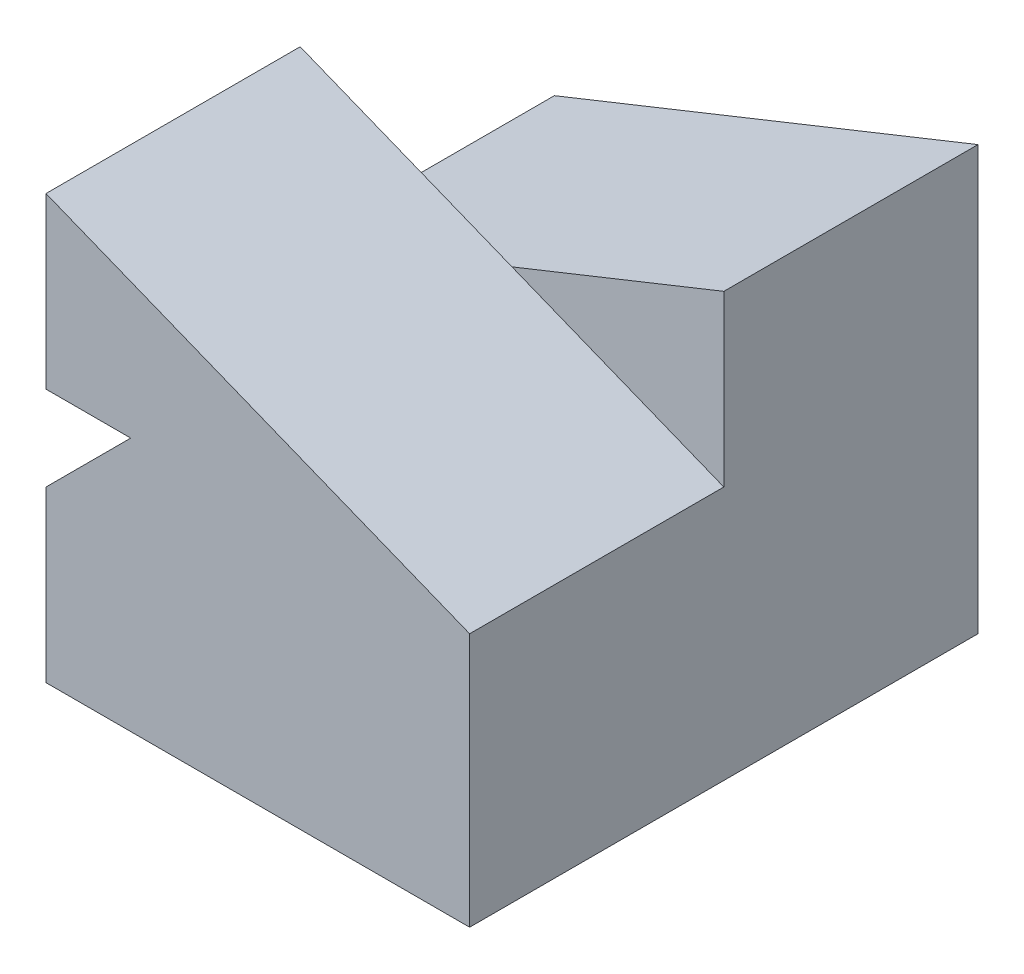
from build123d import *

# Parameters (mm, degrees)
BOSS_EXTRUDE1_DEPTH = 15
BOSS_EXTRUDE2_DEPTH = 15
SKETCH6_W           = 25
SKETCH6_H           = 15
BOSS_EXTRUDE7_DEPTH = 15
BOSS_EXTRUDE8_DEPTH = 15


with BuildPart() as part:
    # Sketch1 → Boss-Extrude1 (new body)
    with BuildSketch(Plane.XY):
        Polygon((-25, 0), (0, 0), (0, 15), (-20, 15), (-25, 10), align=None)
    extrude(amount=BOSS_EXTRUDE1_DEPTH)

    # Sketch2 → Boss-Extrude2 (add)
    with BuildSketch(Plane(origin=(0, 0, 0), x_dir=(-1, 0, 0), z_dir=(0, 0, -1))):
        Polygon((25, 25), (25, 15), (0, 15), align=None)
    extrude(amount=-BOSS_EXTRUDE2_DEPTH)



with BuildPart() as body_2:
    # Sketch6 → Boss-Extrude7 (new body)
    with BuildSketch(Plane(origin=(0, 0, 0), x_dir=(-1, 0, 0), z_dir=(0, 0, -1))):
        with Locations((12.5, 7.5)):
            Rectangle(SKETCH6_W, SKETCH6_H)
    extrude(amount=BOSS_EXTRUDE7_DEPTH)


with BuildPart() as part_1:
    add(part.part)

    add(body_2.part)  # Boss-Extrude8 merges body 2
    # Sketch7 → Boss-Extrude8 (add)
    with BuildSketch(Plane(origin=(0, 0, 0), x_dir=(-1, 0, 0), z_dir=(0, 0, -1))):
        Polygon((0, 15), (0, 25), (25, 15), align=None)
    extrude(amount=BOSS_EXTRUDE8_DEPTH)


solid = part_1.part
